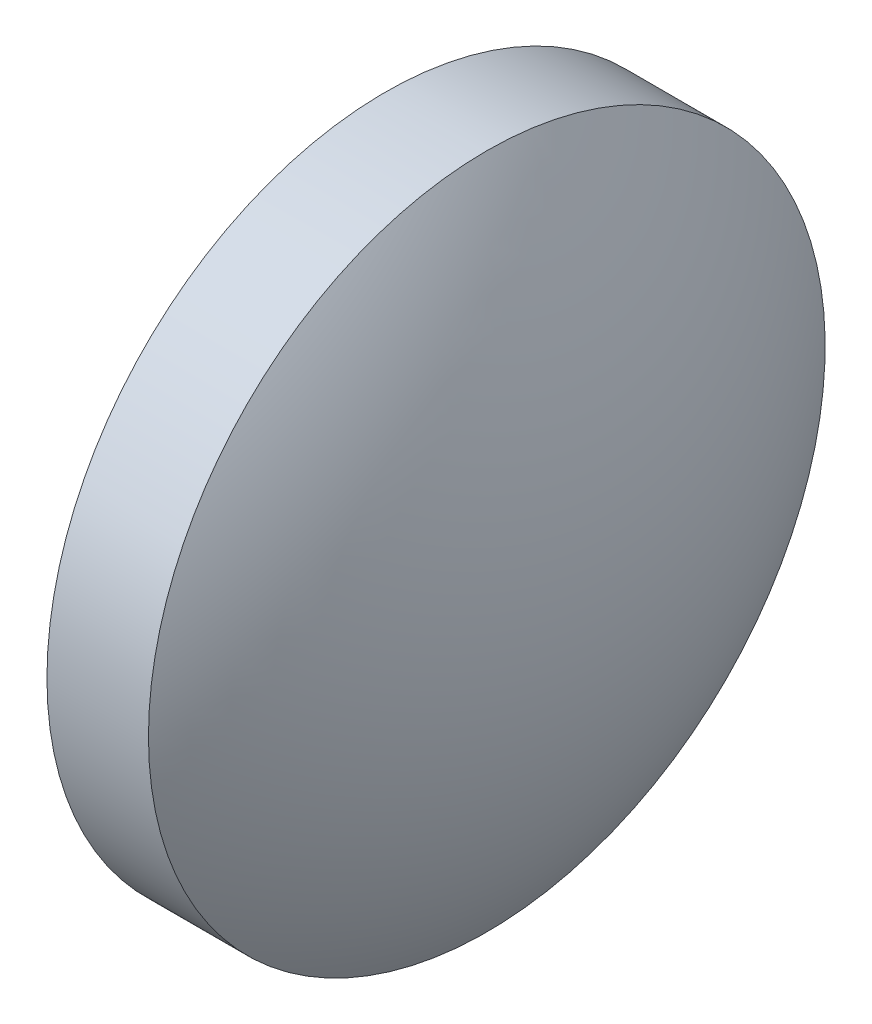
from build123d import *


with BuildPart() as part:
    # 草图1 → 旋转1 (revolve)
    with BuildSketch(Plane.XY):
        with BuildLine():
            Line((364.661815465, 37.064018954), (364.661815465, 42.064018954))
            Line((364.661815465, 42.064018954), (366.161815465, 42.064018954))
            ThreePointArc((366.161815465, 42.064018954), (367.278737556, 39.674095582), (367.661815465, 37.064018954))
            Line((367.661815465, 37.064018954), (364.661815465, 37.064018954))
        make_face()
    revolve(axis=Axis((363.519585773, 37.064018954, 0), (1, 0, 0)))


solid = part.part
